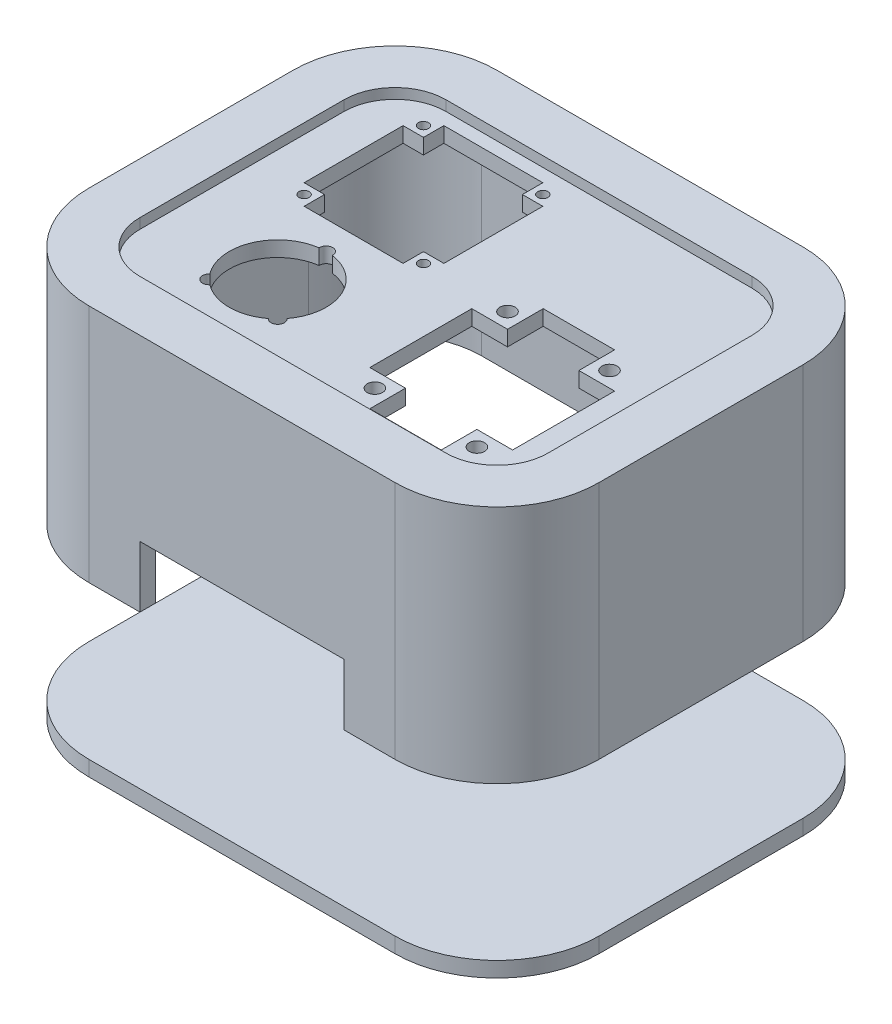
from build123d import *

# Parameters (mm, degrees)
EXTRUDE_1_DEPTH       = 60
EXTRUDE_1_2_DEPTH     = 10
CUT_EXTRUDE_2_DEPTH   = 2
SKETCH_3_R            = 1.5
CUT_EXTRUDE_5_DEPTH   = 61
CUT_EXTRUDE_6_DEPTH   = 59
SKETCH_7_R            = 1
CUT_EXTRUDE_7_DEPTH   = 59
SKETCH_8_W            = 40
SKETCH_8_H            = 25
CUT_EXTRUDE_8_DEPTH   = 10
EXTRUDE_START         = 10
EXTRUDE_2_DEPTH       = 10
EXTRUDE_5_DEPTH       = 10
CUT_EXTRUDE_START     = -5
CUT_EXTRUDE_10_DEPTH  = 10
CUT_EXTRUDE_3_DEPTH   = 55
CUT_EXTRUDE_START_2   = 10
SKETCH_9_8_W          = 60
SKETCH_9_8_H          = 40
CUT_EXTRUDE_4_DEPTH   = 5
CUT_EXTRUDE_12_DEPTH  = 5
CUT_EXTRUDE_5_2_DEPTH = 55
CUT_EXTRUDE_6_2_DEPTH = 13
CUT_EXTRUDE_13_DEPTH  = 7
CUT_EXTRUDE_7_2_DEPTH = 17


with BuildPart() as part:
    # 草图1 → Extrude 1 (new body)
    with BuildSketch(Plane(origin=(0, 0, 0), x_dir=(1, 0, 0), z_dir=(0, 1, 0))):
        with BuildLine():
            Line((10, -10), (70, -10))
            ThreePointArc((70, -10), (84.142135624, -4.142135624), (90, 10))
            Line((90, 10), (90, 50))
            ThreePointArc((90, 50), (84.142135624, 64.142135624), (70, 70))
            Line((70, 70), (10, 70))
            ThreePointArc((10, 70), (-4.142135624, 64.142135624), (-10, 50))
            Line((-10, 50), (-10, 10))
            ThreePointArc((-10, 10), (-4.142135624, -4.142135624), (10, -10))
        make_face()
        with BuildLine():
            Line((10, 0), (70, 0))
            ThreePointArc((70, 0), (77.071067812, 2.928932188), (80, 10))
            Line((80, 10), (80, 50))
            ThreePointArc((80, 50), (77.071067812, 57.071067812), (70, 60))
            Line((70, 60), (10, 60))
            ThreePointArc((10, 60), (2.928932188, 57.071067812), (0, 50))
            Line((0, 50), (0, 10))
            ThreePointArc((0, 10), (2.928932188, 2.928932188), (10, 0))
        make_face(mode=Mode.SUBTRACT)
    extrude(amount=EXTRUDE_1_DEPTH)

    # 草图2 → Extrude 1 2 (add)
    with BuildSketch(Plane(origin=(0, 60, 0), x_dir=(1, 0, 0), z_dir=(0, 1, 0))):
        with BuildLine():
            Line((10, 0), (70, 0))
            ThreePointArc((70, 0), (77.071067812, 2.928932188), (80, 10))
            Line((80, 10), (80, 50))
            ThreePointArc((80, 50), (77.071067812, 57.071067812), (70, 60))
            Line((70, 60), (10, 60))
            ThreePointArc((10, 60), (2.928932188, 57.071067812), (0, 50))
            Line((0, 50), (0, 10))
            ThreePointArc((0, 10), (2.928932188, 2.928932188), (10, 0))
        make_face()
    extrude(amount=-EXTRUDE_1_2_DEPTH)

    # 草图2<6> → 切除-拉伸2 (cut)
    with BuildSketch(Plane(origin=(0, 60, 0), x_dir=(1, 0, 0), z_dir=(0, 1, 0))):
        with BuildLine():
            Line((10, 0), (70, 0))
            ThreePointArc((70, 0), (77.071067812, 2.928932188), (80, 10))
            Line((80, 10), (80, 50))
            ThreePointArc((80, 50), (77.071067812, 57.071067812), (70, 60))
            Line((70, 60), (10, 60))
            ThreePointArc((10, 60), (2.928932188, 57.071067812), (0, 50))
            Line((0, 50), (0, 10))
            ThreePointArc((0, 10), (2.928932188, 2.928932188), (10, 0))
        make_face()
    extrude(amount=-CUT_EXTRUDE_2_DEPTH, mode=Mode.SUBTRACT)

    # 草图3 → Cut-Extrude 5 (cut, through all)
    with BuildSketch(Plane(origin=(0, 60, 0), x_dir=(1, 0, 0), z_dir=(0, 1, 0))):
        with Locations((50, 6.058283931)):
            Circle(SKETCH_3_R)
        with Locations((70, 32.058283931)):
            Circle(SKETCH_3_R)
        with Locations((50, 32.058283931)):
            Circle(SKETCH_3_R)
        Polygon((53, 3.67004288), (53, 9.058283931), (51.136181137, 9.058283931), (46, 9.058283931), (46, 29.058283931), (51, 29.058283931), (53, 29.058283931), (53, 31), (53, 36.058283931), (67, 36.058283931), (67, 32.237823352), (67, 29.058283931), (71, 29.058283931), (74, 29.058283931), (74, 9.058283931), (71.136181137, 9.058283931), (67, 9.058283931), (67, 6.058283931), (67, 2.058283931), (53, 2.058283931), align=None)
        with Locations((70, 6.058283931)):
            Circle(SKETCH_3_R)
    extrude(amount=-CUT_EXTRUDE_5_DEPTH, mode=Mode.SUBTRACT)

    # 草图6 → Cut-Extrude 6 (cut, through all)
    with BuildSketch(Plane(origin=(0, 58, 0), x_dir=(1, 0, 0), z_dir=(0, 1, 0))):
        with BuildLine():
            ThreePointArc((23.296953494, 24.411052632), (22, 25.8), (20.703046506, 24.411052632))
            ThreePointArc((20.703046506, 24.411052632), (13.223144441, 18.635492607), (14.428296256, 9.262465477))
            ThreePointArc((14.428296256, 9.262465477), (14.363246763, 7.363246763), (16.262465477, 7.428296256))
            ThreePointArc((16.262465477, 7.428296256), (22, 5.5), (27.737534523, 7.428296256))
            ThreePointArc((27.737534523, 7.428296256), (29.636753237, 7.363246763), (29.571703744, 9.262465477))
            ThreePointArc((29.571703744, 9.262465477), (30.776855559, 18.635492607), (23.296953494, 24.411052632))
        make_face()
    extrude(amount=-CUT_EXTRUDE_6_DEPTH, mode=Mode.SUBTRACT)

    # 草图7 → Cut-Extrude 7 (cut, through all)
    with BuildSketch(Plane(origin=(0, 58, 0), x_dir=(1, 0, 0), z_dir=(0, 1, 0))):
        Polygon((31.584864034, 30), (31.584864034, 32), (31.584864034, 34), (35.584864034, 34), (35.584864034, 53.4), (31.584864034, 53.4), (31.584864034, 55.4), (31.584864034, 57.4), (12.184864034, 57.4), (12.184864034, 53.4), (10.184864034, 53.4), (8.184864034, 53.4), (8.184864034, 34), (12.184864034, 34), (12.184864034, 32), (12.184864034, 30), align=None)
        with Locations((33.584864034, 32)):
            Circle(SKETCH_7_R)
        with Locations((10.184864034, 55.4)):
            Circle(SKETCH_7_R)
        with Locations((33.584864034, 55.4)):
            Circle(SKETCH_7_R)
        with Locations((10.184864034, 32)):
            Circle(SKETCH_7_R)
    extrude(amount=-CUT_EXTRUDE_7_DEPTH, mode=Mode.SUBTRACT)

    # 草图8 → 切除-拉伸8 (cut)
    with BuildSketch(Plane.XY.offset(10)):
        with Locations((40, 12.5)):
            Rectangle(SKETCH_8_W, SKETCH_8_H)
    extrude(amount=-CUT_EXTRUDE_8_DEPTH, mode=Mode.SUBTRACT)

    # 草图2<8> → 切除-拉伸10 (cut)
    with BuildSketch(Plane(origin=(0, 60, 0), x_dir=(1, 0, 0), z_dir=(0, 1, 0)).offset(CUT_EXTRUDE_START)):
        with BuildLine():
            Line((10, 0), (70, 0))
            ThreePointArc((70, 0), (77.071067812, 2.928932188), (80, 10))
            Line((80, 10), (80, 50))
            ThreePointArc((80, 50), (77.071067812, 57.071067812), (70, 60))
            Line((70, 60), (10, 60))
            ThreePointArc((10, 60), (2.928932188, 57.071067812), (0, 50))
            Line((0, 50), (0, 10))
            ThreePointArc((0, 10), (2.928932188, 2.928932188), (10, 0))
        make_face()
    extrude(amount=-CUT_EXTRUDE_10_DEPTH, mode=Mode.SUBTRACT)

    # 草图9<7> → 切除-拉伸-薄壁3 (cut)
    with BuildSketch(Plane.XZ):
        with BuildLine():
            Line((85, -10), (85, -50))
            ThreePointArc((85, -50), (80.606601718, -60.606601718), (70, -65))
            Line((70, -65), (10, -65))
            ThreePointArc((10, -65), (-0.606601718, -60.606601718), (-5, -50))
            Line((-5, -50), (-5, -10))
            ThreePointArc((-5, -10), (-0.606601718, 0.606601718), (10, 5))
            Line((10, 5), (70, 5))
            ThreePointArc((70, 5), (80.606601718, 0.606601718), (85, -10))
        make_face()
        with BuildLine():
            Line((75, -10), (75, -50))
            ThreePointArc((75, -50), (73.535533906, -53.535533906), (70, -55))
            Line((70, -55), (10, -55))
            ThreePointArc((10, -55), (6.464466094, -53.535533906), (5, -50))
            Line((5, -50), (5, -10))
            ThreePointArc((5, -10), (6.464466094, -6.464466094), (10, -5))
            Line((10, -5), (70, -5))
            ThreePointArc((70, -5), (73.535533906, -6.464466094), (75, -10))
        make_face(mode=Mode.SUBTRACT)
    extrude(amount=-CUT_EXTRUDE_3_DEPTH, mode=Mode.SUBTRACT)

    # 草图9<10> → Cut-Extrude 5 2 (cut)
    with BuildSketch(Plane.XZ):
        with BuildLine():
            Line((87, -10), (87, -50))
            ThreePointArc((87, -50), (82.02081528, -62.02081528), (70, -67))
            Line((70, -67), (10, -67))
            ThreePointArc((10, -67), (-2.02081528, -62.02081528), (-7, -50))
            Line((-7, -50), (-7, -10))
            ThreePointArc((-7, -10), (-2.02081528, 2.02081528), (10, 7))
            Line((10, 7), (70, 7))
            ThreePointArc((70, 7), (82.02081528, 2.02081528), (87, -10))
        make_face()
        with BuildLine():
            Line((80, -10), (80, -50))
            ThreePointArc((80, -50), (77.071067812, -57.071067812), (70, -60))
            Line((70, -60), (10, -60))
            ThreePointArc((10, -60), (2.928932188, -57.071067812), (0, -50))
            Line((0, -50), (0, -10))
            ThreePointArc((0, -10), (2.928932188, -2.928932188), (10, 0))
            Line((10, 0), (70, 0))
            ThreePointArc((70, 0), (77.071067812, -2.928932188), (80, -10))
        make_face(mode=Mode.SUBTRACT)
    extrude(amount=-CUT_EXTRUDE_5_2_DEPTH, mode=Mode.SUBTRACT)

    # 草图9<11> → Cut-Extrude 6 2 (cut)
    with BuildSketch(Plane.XZ):
        with BuildLine():
            Line((90, -10), (90, -50))
            ThreePointArc((90, -50), (84.142135624, -64.142135624), (70, -70))
            Line((70, -70), (10, -70))
            ThreePointArc((10, -70), (-4.142135624, -64.142135624), (-10, -50))
            Line((-10, -50), (-10, -10))
            ThreePointArc((-10, -10), (-4.142135624, 4.142135624), (10, 10))
            Line((10, 10), (70, 10))
            ThreePointArc((70, 10), (84.142135624, 4.142135624), (90, -10))
        make_face()
        with BuildLine():
            Line((80, -10), (80, -50))
            ThreePointArc((80, -50), (77.071067812, -57.071067812), (70, -60))
            Line((70, -60), (10, -60))
            ThreePointArc((10, -60), (2.928932188, -57.071067812), (0, -50))
            Line((0, -50), (0, -10))
            ThreePointArc((0, -10), (2.928932188, -2.928932188), (10, 0))
            Line((10, 0), (70, 0))
            ThreePointArc((70, 0), (77.071067812, -2.928932188), (80, -10))
        make_face(mode=Mode.SUBTRACT)
    extrude(amount=-CUT_EXTRUDE_6_2_DEPTH, mode=Mode.SUBTRACT)


with BuildPart() as body_2:
    # 草图9 → 凸台-拉伸2 (new body)
    with BuildSketch(Plane.XZ.offset(EXTRUDE_START)):
        with BuildLine():
            Line((10, 0), (70, 0))
            ThreePointArc((70, 0), (77.071067812, -2.928932188), (80, -10))
            Line((80, -10), (80, -50))
            ThreePointArc((80, -50), (77.071067812, -57.071067812), (70, -60))
            Line((70, -60), (10, -60))
            ThreePointArc((10, -60), (2.928932188, -57.071067812), (0, -50))
            Line((0, -50), (0, -10))
            ThreePointArc((0, -10), (2.928932188, -2.928932188), (10, 0))
        make_face()
    extrude(amount=EXTRUDE_2_DEPTH)

    # 草图10 → 拉伸-薄壁5 (add)
    with BuildSketch(Plane.XZ.offset(EXTRUDE_START)):
        with BuildLine():
            Line((10, 10), (70, 10))
            ThreePointArc((70, 10), (84.142135624, 4.142135624), (90, -10))
            Line((90, -10), (90, -50))
            ThreePointArc((90, -50), (84.142135624, -64.142135624), (70, -70))
            Line((70, -70), (10, -70))
            ThreePointArc((10, -70), (-4.142135624, -64.142135624), (-10, -50))
            Line((-10, -50), (-10, -10))
            ThreePointArc((-10, -10), (-4.142135624, 4.142135624), (10, 10))
        make_face()
        with BuildLine():
            Line((10, 0), (70, 0))
            ThreePointArc((70, 0), (77.071067812, -2.928932188), (80, -10))
            Line((80, -10), (80, -50))
            ThreePointArc((80, -50), (77.071067812, -57.071067812), (70, -60))
            Line((70, -60), (10, -60))
            ThreePointArc((10, -60), (2.928932188, -57.071067812), (0, -50))
            Line((0, -50), (0, -10))
            ThreePointArc((0, -10), (2.928932188, -2.928932188), (10, 0))
        make_face(mode=Mode.SUBTRACT)
    extrude(amount=EXTRUDE_5_DEPTH)

    # 草图9<8> → 切除-拉伸-薄壁4 (cut)
    with BuildSketch(Plane.XZ.offset(CUT_EXTRUDE_START_2)):
        with BuildLine():
            Line((90, -10), (90, -50))
            ThreePointArc((90, -50), (84.142135624, -64.142135624), (70, -70))
            Line((70, -70), (10, -70))
            ThreePointArc((10, -70), (-4.142135624, -64.142135624), (-10, -50))
            Line((-10, -50), (-10, -10))
            ThreePointArc((-10, -10), (-4.142135624, 4.142135624), (10, 10))
            Line((10, 10), (70, 10))
            ThreePointArc((70, 10), (84.142135624, 4.142135624), (90, -10))
        make_face()
        with Locations((40, -30)):
            Rectangle(SKETCH_9_8_W, SKETCH_9_8_H, mode=Mode.SUBTRACT)
    extrude(amount=CUT_EXTRUDE_4_DEPTH, mode=Mode.SUBTRACT)

    # 草图9<9> → 切除-拉伸12 (cut)
    with BuildSketch(Plane.XZ.offset(CUT_EXTRUDE_START_2)):
        with BuildLine():
            Line((10, 0), (70, 0))
            ThreePointArc((70, 0), (77.071067812, -2.928932188), (80, -10))
            Line((80, -10), (80, -50))
            ThreePointArc((80, -50), (77.071067812, -57.071067812), (70, -60))
            Line((70, -60), (10, -60))
            ThreePointArc((10, -60), (2.928932188, -57.071067812), (0, -50))
            Line((0, -50), (0, -10))
            ThreePointArc((0, -10), (2.928932188, -2.928932188), (10, 0))
        make_face()
    extrude(amount=CUT_EXTRUDE_12_DEPTH, mode=Mode.SUBTRACT)

    # 草图9<12> → 切除-拉伸13 (cut)
    with BuildSketch(Plane.XZ.offset(CUT_EXTRUDE_START_2)):
        with BuildLine():
            Line((10, 0), (70, 0))
            ThreePointArc((70, 0), (77.071067812, -2.928932188), (80, -10))
            Line((80, -10), (80, -50))
            ThreePointArc((80, -50), (77.071067812, -57.071067812), (70, -60))
            Line((70, -60), (10, -60))
            ThreePointArc((10, -60), (2.928932188, -57.071067812), (0, -50))
            Line((0, -50), (0, -10))
            ThreePointArc((0, -10), (2.928932188, -2.928932188), (10, 0))
        make_face()
    extrude(amount=CUT_EXTRUDE_13_DEPTH, mode=Mode.SUBTRACT)

    # 草图9<13> → Cut-Extrude 7 2 (cut)
    with BuildSketch(Plane.XZ):
        with BuildLine():
            Line((90, -10), (90, -50))
            ThreePointArc((90, -50), (84.142135624, -64.142135624), (70, -70))
            Line((70, -70), (10, -70))
            ThreePointArc((10, -70), (-4.142135624, -64.142135624), (-10, -50))
            Line((-10, -50), (-10, -10))
            ThreePointArc((-10, -10), (-4.142135624, 4.142135624), (10, 10))
            Line((10, 10), (70, 10))
            ThreePointArc((70, 10), (84.142135624, 4.142135624), (90, -10))
        make_face()
        with BuildLine():
            Line((80, -10), (80, -50))
            ThreePointArc((80, -50), (77.071067812, -57.071067812), (70, -60))
            Line((70, -60), (10, -60))
            ThreePointArc((10, -60), (2.928932188, -57.071067812), (0, -50))
            Line((0, -50), (0, -10))
            ThreePointArc((0, -10), (2.928932188, -2.928932188), (10, 0))
            Line((10, 0), (70, 0))
            ThreePointArc((70, 0), (77.071067812, -2.928932188), (80, -10))
        make_face(mode=Mode.SUBTRACT)
    extrude(amount=CUT_EXTRUDE_7_2_DEPTH, mode=Mode.SUBTRACT)


solid = Compound([part.part, body_2.part])
